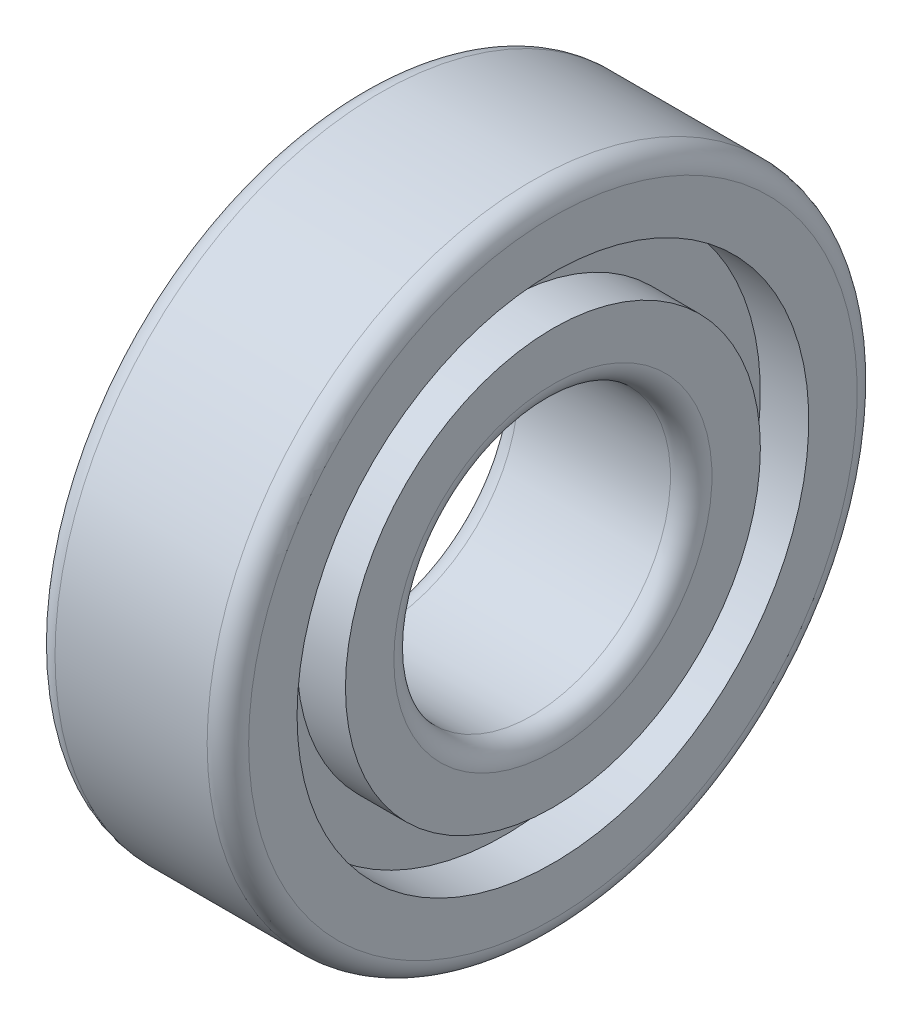
from build123d import *


with BuildPart() as part:
    # Эскиз1 → Повернуть1 (revolve)
    with BuildSketch(Plane.XY):
        with BuildLine():
            Line((5.5, 10), (-5.5, 10))
            ThreePointArc((-5.5, 10), (-6.560660172, 10.439339828), (-7, 11.5))
            Line((-7, 11.5), (-7, 15))
            Line((-7, 15), (-3.5, 15))
            Line((-3.5, 15), (-3.5, 18.5))
            Line((-3.5, 18.5), (-7, 18.5))
            Line((-7, 18.5), (-7, 22))
            ThreePointArc((-7, 22), (-6.560660172, 23.060660172), (-5.5, 23.5))
            Line((-5.5, 23.5), (5.5, 23.5))
            ThreePointArc((5.5, 23.5), (6.560660172, 23.060660172), (7, 22))
            Line((7, 22), (7, 18.5))
            Line((7, 18.5), (3.5, 18.5))
            Line((3.5, 18.5), (3.5, 15))
            Line((3.5, 15), (7, 15))
            Line((7, 15), (7, 11.5))
            ThreePointArc((7, 11.5), (6.560660172, 10.439339828), (5.5, 10))
        make_face()
    revolve(axis=Axis((-873.991742101, 0, 0), (1, 0, 0)))


solid = part.part
